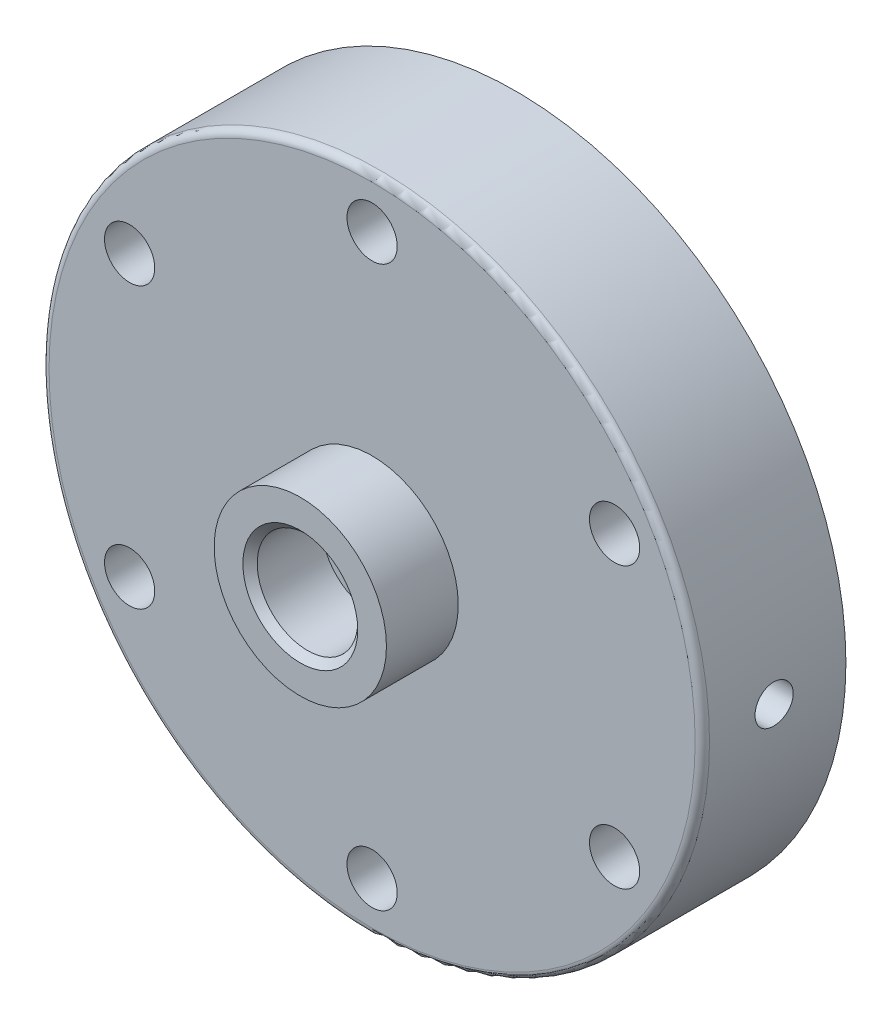
from build123d import *

# Parameters (mm, degrees)
SKETCH2_R               = 46
SKETCH2_R_2             = 3.5
SKETCH2_R_3             = 2.5
BOSS_EXTRUDE1_DEPTH     = 20
SKETCH3_R               = 12
SKETCH3_R_2             = 7
BOSS_EXTRUDE2_DEPTH     = 10
CHAMFER1_SIZE           = 1
SKETCH6_R               = 33
CUT_EXTRUDE1_DEPTH      = 14
FILLET1_R               = 1
SKETCH7_R               = 2.66023902
CUT_EXTRUDE2_DEPTH      = 47
CUT_EXTRUDE2_DEPTH_BACK = 47


with BuildPart() as part:
    # Sketch2 → Boss-Extrude1 (new body)
    with BuildSketch(Plane.XY):
        Circle(SKETCH2_R)
        with Locations((0, 39)):
            Circle(SKETCH2_R_2, mode=Mode.SUBTRACT)
        Circle(SKETCH2_R_3, mode=Mode.SUBTRACT)
        with Locations((33.774990748, 19.5)):
            Circle(SKETCH2_R_2, mode=Mode.SUBTRACT)
        with Locations((33.774990748, -19.5)):
            Circle(SKETCH2_R_2, mode=Mode.SUBTRACT)
        with Locations((0, -39)):
            Circle(SKETCH2_R_2, mode=Mode.SUBTRACT)
        with Locations((-33.774990748, -19.5)):
            Circle(SKETCH2_R_2, mode=Mode.SUBTRACT)
        with Locations((-33.774990748, 19.5)):
            Circle(SKETCH2_R_2, mode=Mode.SUBTRACT)
    extrude(amount=BOSS_EXTRUDE1_DEPTH)

    # Sketch3 → Boss-Extrude2 (add)
    with BuildSketch(Plane.XY.offset(20)):
        Circle(SKETCH3_R)
        Circle(SKETCH3_R_2, mode=Mode.SUBTRACT)
    extrude(amount=BOSS_EXTRUDE2_DEPTH)

    # Chamfer1
    chamfer1_edges = [part.edges().sort_by_distance(p)[0] for p in [
        (-7, 0, 30),
    ]]
    chamfer(chamfer1_edges, length=CHAMFER1_SIZE)

    # Sketch6 → Cut-Extrude1 (cut)
    with BuildSketch(Plane(origin=(0, 0, 0), x_dir=(-1, 0, 0), z_dir=(0, 0, -1))):
        Circle(SKETCH6_R)
    extrude(amount=-CUT_EXTRUDE1_DEPTH, mode=Mode.SUBTRACT)

    # Fillet1
    fillet1_edges = [part.edges().sort_by_distance(p)[0] for p in [
        (-46, 0, 20),
    ]]
    fillet(fillet1_edges, radius=FILLET1_R)

    # Sketch7 → Cut-Extrude2 (cut, two sides)
    with BuildSketch(Plane(origin=(0, 0, 0), x_dir=(0, 0, -1), z_dir=(1, 0, 0))) as cut_extrude2_sk:
        with Locations((-10, 0)):
            Circle(SKETCH7_R)
    extrude(amount=CUT_EXTRUDE2_DEPTH, mode=Mode.SUBTRACT)
    extrude(cut_extrude2_sk.sketch, amount=-CUT_EXTRUDE2_DEPTH_BACK, mode=Mode.SUBTRACT)


solid = part.part
